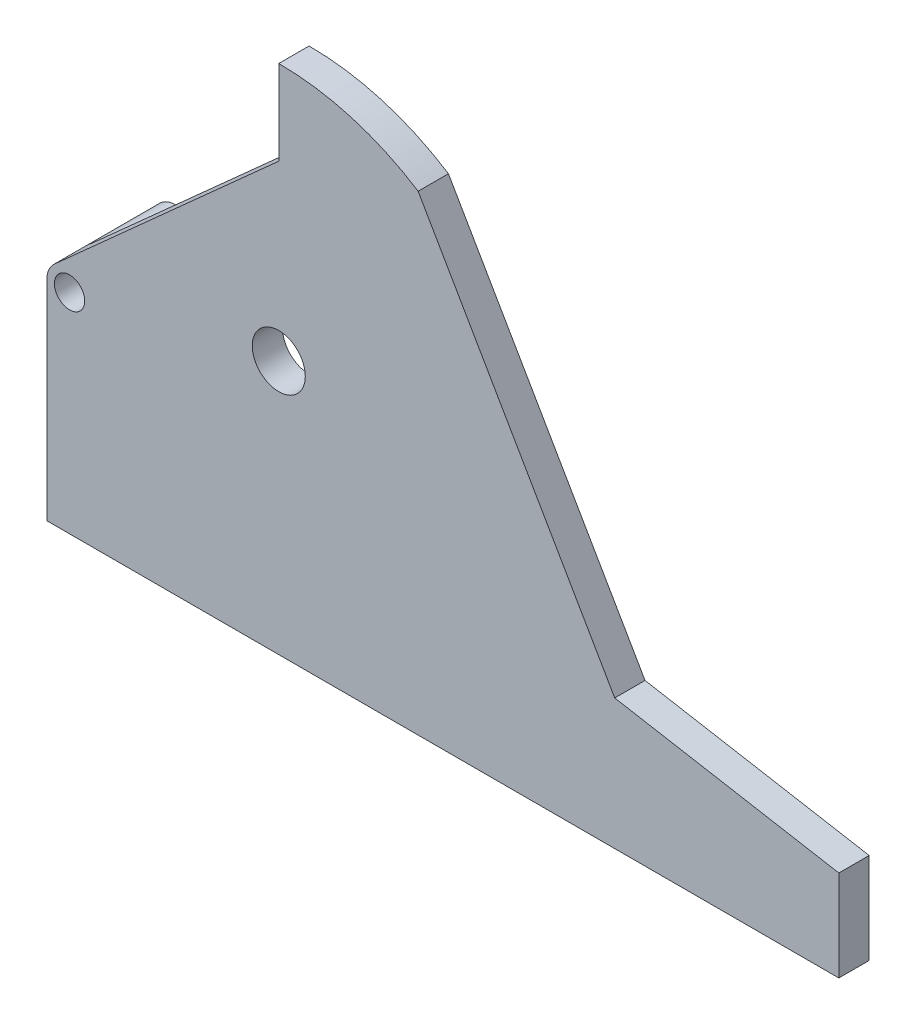
from build123d import *

# Parameters (mm, degrees)
SKETCH1_R           = 17.5
SKETCH1_R_2         = 10
BOSS_EXTRUDE1_DEPTH = 20
SKETCH2_R           = 15
SKETCH2_R_2         = 10
BOSS_EXTRUDE2_DEPTH = 70


with BuildPart() as part:
    # Sketch1 → Boss-Extrude1 (new body)
    with BuildSketch(Plane.XY):
        with BuildLine():
            Line((0, 138), (0, 0))
            Line((0, 0), (522.5, 0))
            Line((522.5, 0), (522.5, 60))
            Line((522.5, 60), (374.6494, 86.07005))
            Line((374.6494, 86.07005), (244.94, 310.733321))
            ThreePointArc((244.94, 310.733321), (200.912249, 330.84879), (153, 337.740187))
            Line((153, 337.740187), (153, 281.918848))
            Line((153, 281.918848), (4.984782, 149.16671))
            ThreePointArc((4.984782, 149.16671), (1.302769, 144.114398), (0, 138))
        make_face()
        with Locations((153, 167.740187)):
            Circle(SKETCH1_R, mode=Mode.SUBTRACT)
        with Locations((15, 138)):
            Circle(SKETCH1_R_2, mode=Mode.SUBTRACT)
    extrude(amount=BOSS_EXTRUDE1_DEPTH)

    # Sketch2 → Boss-Extrude2 (add)
    with BuildSketch(Plane.XY.offset(20)):
        with Locations((15, 138)):
            Circle(SKETCH2_R)
        with Locations((15, 138)):
            Circle(SKETCH2_R_2, mode=Mode.SUBTRACT)
    extrude(amount=-BOSS_EXTRUDE2_DEPTH)


solid = part.part
